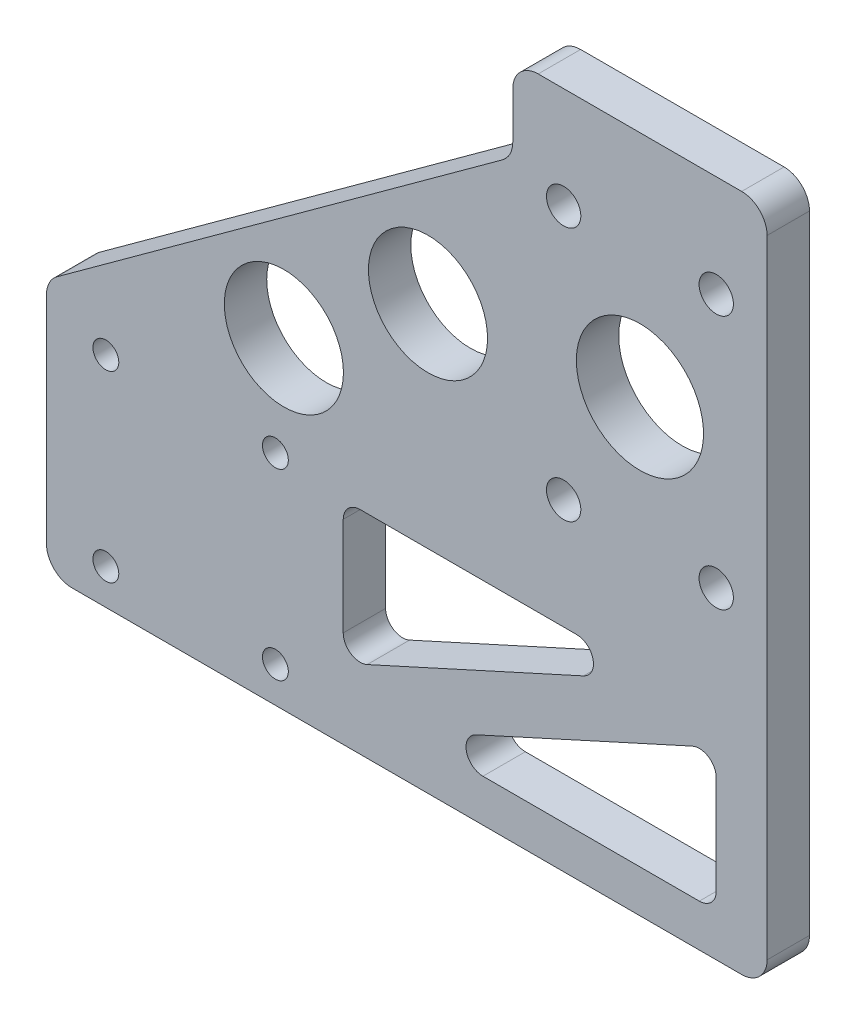
from build123d import *

# Parameters (mm, degrees)
EXTRUDE_1_DEPTH          = 5
EXTRUDE_2_DEPTH          = 5
CUT_EXTRUDE_1_DEPTH      = 5
CUT_EXTRUDE_2_REACH      = 7
SKETCH_5_R               = 1.524999999
SKETCH_6_R               = 2.025
CUT_EXTRUDE_3_DEPTH      = 1
CUT_EXTRUDE_3_DEPTH_BACK = 6
CUT_EXTRUDE_4_DEPTH      = 6
FILLET_4_R               = 2
SKETCH_8_R               = 7.5
CUT_EXTRUDE_5_DEPTH      = 5
EXTRUDE_3_DEPTH          = 5
SKETCH_10_R              = 7.025
CUT_EXTRUDE_6_DEPTH      = 5
FILLET_5_R               = 3


with BuildPart() as part:
    # 草图1 → 凸台-拉伸1 (new body)
    with BuildSketch(Plane.XY):
        Polygon((0, 0), (-55, 0), (-55, -30), (30, -30), (30, 50), (0, 50), align=None)
    extrude(amount=EXTRUDE_1_DEPTH)

    # 草图2 → 凸台-拉伸2 (add)
    with BuildSketch(Plane.XY.offset(5)):
        Polygon((0, 40), (-45, 0), (0, 0), align=None)
    extrude(amount=-EXTRUDE_2_DEPTH)

    # 草图4 → 切除-拉伸1 (cut)
    with BuildSketch(Plane.XY.offset(5)):
        Polygon((0, 33.310225234), (0, 0), (-37.474003388, 0), align=None)
    extrude(amount=-CUT_EXTRUDE_1_DEPTH, mode=Mode.SUBTRACT)

    # 草图5 → 切除-拉伸2 (cut, up to next)
    with BuildSketch(Plane(origin=(0, 0, 0), x_dir=(-1, 0, 0), z_dir=(0, 0, -1)), mode=Mode.PRIVATE) as cut_extrude_2_sk1:
        with Locations((48, -4.2)):
            Circle(SKETCH_5_R)
    cut_extrude_2_tool1 = extrude(cut_extrude_2_sk1.sketch, amount=-CUT_EXTRUDE_2_REACH, mode=Mode.PRIVATE) & part.part
    add(cut_extrude_2_tool1.solids().sort_by_distance((-48, -4.2, 0))[0], mode=Mode.SUBTRACT)
    # 草图5 → 切除-拉伸2 (cut, up to next)
    with BuildSketch(Plane(origin=(0, 0, 0), x_dir=(-1, 0, 0), z_dir=(0, 0, -1)), mode=Mode.PRIVATE) as cut_extrude_2_sk2:
        with Locations((48, -25.8)):
            Circle(SKETCH_5_R)
    cut_extrude_2_tool2 = extrude(cut_extrude_2_sk2.sketch, amount=-CUT_EXTRUDE_2_REACH, mode=Mode.PRIVATE) & part.part
    add(cut_extrude_2_tool2.solids().sort_by_distance((-48, -25.8, 0))[0], mode=Mode.SUBTRACT)
    # 草图5 → 切除-拉伸2 (cut, up to next)
    with BuildSketch(Plane(origin=(0, 0, 0), x_dir=(-1, 0, 0), z_dir=(0, 0, -1)), mode=Mode.PRIVATE) as cut_extrude_2_sk3:
        with Locations((28, -4.2)):
            Circle(SKETCH_5_R)
    cut_extrude_2_tool3 = extrude(cut_extrude_2_sk3.sketch, amount=-CUT_EXTRUDE_2_REACH, mode=Mode.PRIVATE) & part.part
    add(cut_extrude_2_tool3.solids().sort_by_distance((-28, -4.2, 0))[0], mode=Mode.SUBTRACT)
    # 草图5 → 切除-拉伸2 (cut, up to next)
    with BuildSketch(Plane(origin=(0, 0, 0), x_dir=(-1, 0, 0), z_dir=(0, 0, -1)), mode=Mode.PRIVATE) as cut_extrude_2_sk4:
        with Locations((28, -25.8)):
            Circle(SKETCH_5_R)
    cut_extrude_2_tool4 = extrude(cut_extrude_2_sk4.sketch, amount=-CUT_EXTRUDE_2_REACH, mode=Mode.PRIVATE) & part.part
    add(cut_extrude_2_tool4.solids().sort_by_distance((-28, -25.8, 0))[0], mode=Mode.SUBTRACT)

    # 草图6 → 切除-拉伸3 (cut, two sides)
    with BuildSketch(Plane(origin=(0, 0, 0), x_dir=(-1, 0, 0), z_dir=(0, 0, -1))) as cut_extrude_3_sk:
        with Locations((-6, 38)):
            Circle(SKETCH_6_R)
        with Locations((-24, 38)):
            Circle(SKETCH_6_R)
        with Locations((-24, 8)):
            Circle(SKETCH_6_R)
        with Locations((-6, 8)):
            Circle(SKETCH_6_R)
    extrude(amount=CUT_EXTRUDE_3_DEPTH, mode=Mode.SUBTRACT)
    extrude(cut_extrude_3_sk.sketch, amount=-CUT_EXTRUDE_3_DEPTH_BACK, mode=Mode.SUBTRACT)

    # 草图7 → 切除-拉伸4 (cut, through all)
    with BuildSketch(Plane(origin=(0, 0, 0), x_dir=(-1, 0, 0), z_dir=(0, 0, -1))):
        Polygon((12.750172416, -25), (-24, -8.295376175), (-24, -25), align=None)
        Polygon((20, -5), (-16.750172416, -5), (20, -21.704623825), align=None)
    extrude(amount=-CUT_EXTRUDE_4_DEPTH, mode=Mode.SUBTRACT)

    # 圆角4
    fillet_4_edges = [part.edges().sort_by_distance(p)[0] for p in [
        (16.750172416, -5, 2.5),
        (-20, -5, 2.5),
        (-20, -21.704623825, 2.5),
        (24, -8.295376175, 2.5),
        (-12.750172416, -25, 2.5),
        (24, -25, 2.5),
    ]]
    fillet(fillet_4_edges, radius=FILLET_4_R)

    # 草图8 → 切除-拉伸5 (cut)
    with BuildSketch(Plane(origin=(0, 0, 0), x_dir=(-1, 0, 0), z_dir=(0, 0, -1))):
        with Locations((-15, 23)):
            Circle(SKETCH_8_R)
    extrude(amount=-CUT_EXTRUDE_5_DEPTH, mode=Mode.SUBTRACT)

    # 草图9 → 凸台-拉伸3 (add)
    with BuildSketch(Plane.XY.offset(5)):
        Polygon((-55, 0), (0, 40), (0, 0), align=None)
    extrude(amount=-EXTRUDE_3_DEPTH)

    # 草图10 → 切除-拉伸6 (cut)
    with BuildSketch(Plane.XY.offset(5)):
        with Locations((-27, 8)):
            Circle(SKETCH_10_R)
        with Locations((-10, 20)):
            Circle(SKETCH_10_R)
    extrude(amount=-CUT_EXTRUDE_6_DEPTH, mode=Mode.SUBTRACT)

    # 圆角5
    fillet_5_edges = [part.edges().sort_by_distance(p)[0] for p in [
        (0, 50, 2.5),
        (30, 50, 2.5),
        (30, -30, 2.5),
        (-55, -30, 2.5),
        (-55, 0, 2.5),
        (0, 40, 2.5),
    ]]
    fillet(fillet_5_edges, radius=FILLET_5_R)


solid = part.part
